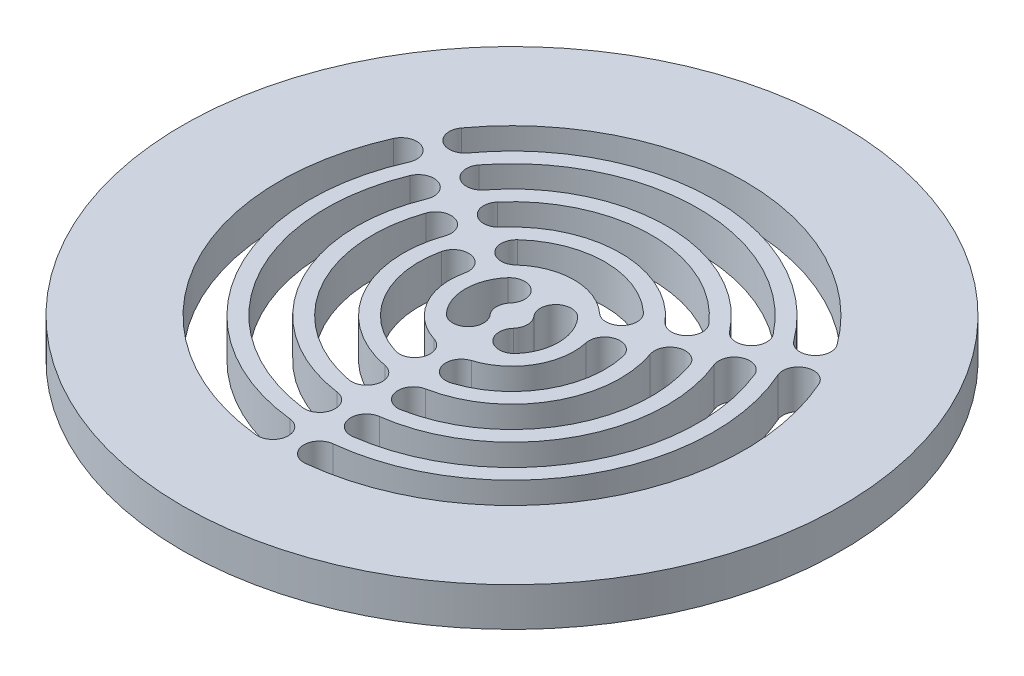
from build123d import *

# Parameters (mm, degrees)
MODEL_R                         = 42.5
AUFSATZ_LINEAR_AUSTRAGEN1_DEPTH = 5


with BuildPart() as part:
    # Model → Aufsatz-Linear austragen1 (new body)
    with BuildSketch(Plane.XZ):
        with Locations(Location((0, 0, 0), (0, 0, 270))):  # turned: the seam where the file's is
            Circle(MODEL_R)
        with BuildLine():
            ThreePointArc((4.5, -3.968626967), (6, 0), (4.5, 3.968626967))
            ThreePointArc((4.5, 3.968626967), (1.677124344, 4.145751311), (1.5, 1.322875656))
            ThreePointArc((1.5, 1.322875656), (2, 0), (1.5, -1.322875656))
            ThreePointArc((1.5, -1.322875656), (1.677124344, -4.145751311), (4.5, -3.968626967))
        make_face(mode=Mode.SUBTRACT)
        with BuildLine():
            ThreePointArc((-1.5, 1.322875656), (-1.677124344, 4.145751311), (-4.5, 3.968626967))
            ThreePointArc((-4.5, 3.968626967), (-6, 0), (-4.5, -3.968626967))
            ThreePointArc((-4.5, -3.968626967), (-1.677124344, -4.145751311), (-1.5, -1.322875656))
            ThreePointArc((-1.5, -1.322875656), (-2, 0), (-1.5, 1.322875656))
        make_face(mode=Mode.SUBTRACT)
        with BuildLine():
            ThreePointArc((-5.409084657, -5.894217775), (-8.234910265, -6.015501054), (-8.113626985, -8.841326662))
            ThreePointArc((-8.113626985, -8.841326662), (0, -12), (8.113626985, -8.841326662))
            ThreePointArc((8.113626985, -8.841326662), (8.234910265, -6.015501054), (5.409084657, -5.894217775))
            ThreePointArc((5.409084657, -5.894217775), (0, -8), (-5.409084657, -5.894217775))
        make_face(mode=Mode.SUBTRACT)
        with BuildLine():
            ThreePointArc((7.809084657, -1.737295837), (9.327031862, -4.12389096), (11.713626985, -2.605943755))
            ThreePointArc((11.713626985, -2.605943755), (10.392304845, 6), (3.6, 11.447270417))
            ThreePointArc((3.6, 11.447270417), (1.092121597, 10.139392014), (2.4, 7.631513611))
            ThreePointArc((2.4, 7.631513611), (6.92820323, 4), (7.809084657, -1.737295837))
        make_face(mode=Mode.SUBTRACT)
        with BuildLine():
            ThreePointArc((-10.59682539, -9.149168905), (-13.417681718, -8.942360836), (-13.624489787, -11.763217163))
            ThreePointArc((-13.624489787, -11.763217163), (0, -18), (13.624489787, -11.763217163))
            ThreePointArc((13.624489787, -11.763217163), (13.417681718, -8.942360836), (10.59682539, -9.149168905))
            ThreePointArc((10.59682539, -9.149168905), (0, -14), (-10.59682539, -9.149168905))
        make_face(mode=Mode.SUBTRACT)
        with BuildLine():
            ThreePointArc((13.22182539, -4.602535535), (14.453152512, -7.14887281), (16.999489787, -5.917545688))
            ThreePointArc((16.999489787, -5.917545688), (15.588457268, 9), (3.375, 17.680762851))
            ThreePointArc((3.375, 17.680762851), (1.035470794, 16.091233646), (2.625, 13.75170444))
            ThreePointArc((2.625, 13.75170444), (12.124355653, 7), (13.22182539, -4.602535535))
        make_face(mode=Mode.SUBTRACT)
        with BuildLine():
            ThreePointArc((-3.214285714, 29.827309087), (-25.980762114, 15), (-27.438350253, -12.13000146))
            ThreePointArc((-27.438350253, -12.13000146), (-24.800460139, -13.150558046), (-23.779903552, -10.512667932))
            ThreePointArc((-23.779903552, -10.512667932), (-22.516660498, 13), (-2.785714286, 25.850334542))
            ThreePointArc((-2.785714286, 25.850334542), (-1.011512728, 28.053107528), (-3.214285714, 29.827309087))
        make_face(mode=Mode.SUBTRACT)
        with BuildLine():
            ThreePointArc((-22.226821187, -9.053641252), (-19.620115984, -10.151406246), (-18.522350989, -7.544701043))
            ThreePointArc((-18.522350989, -7.544701043), (-17.320508076, 10), (-2.727272727, 19.813177016))
            ThreePointArc((-2.727272727, 19.813177016), (-1.018682298, 22.06722199), (-3.272727273, 23.775812419))
            ThreePointArc((-3.272727273, 23.775812419), (-20.784609691, 12), (-22.226821187, -9.053641252))
        make_face(mode=Mode.SUBTRACT)
        with BuildLine():
            ThreePointArc((-2.4, 7.631513611), (-1.092121597, 10.139392014), (-3.6, 11.447270417))
            ThreePointArc((-3.6, 11.447270417), (-10.392304845, 6), (-11.713626985, -2.605943755))
            ThreePointArc((-11.713626985, -2.605943755), (-9.327031862, -4.12389096), (-7.809084657, -1.737295837))
            ThreePointArc((-7.809084657, -1.737295837), (-6.92820323, 4), (-2.4, 7.631513611))
        make_face(mode=Mode.SUBTRACT)
        with BuildLine():
            ThreePointArc((-2.625, 13.75170444), (-1.035470794, 16.091233646), (-3.375, 17.680762851))
            ThreePointArc((-3.375, 17.680762851), (-15.588457268, 9), (-16.999489787, -5.917545688))
            ThreePointArc((-16.999489787, -5.917545688), (-14.453152512, -7.14887281), (-13.22182539, -4.602535535))
            ThreePointArc((-13.22182539, -4.602535535), (-12.124355653, 7), (-2.625, 13.75170444))
        make_face(mode=Mode.SUBTRACT)
        with BuildLine():
            ThreePointArc((27.438350253, -12.13000146), (25.980762114, 15), (3.214285714, 29.827309087))
            ThreePointArc((3.214285714, 29.827309087), (1.011512728, 28.053107528), (2.785714286, 25.850334542))
            ThreePointArc((2.785714286, 25.850334542), (22.516660498, 13), (23.779903552, -10.512667932))
            ThreePointArc((23.779903552, -10.512667932), (24.800460139, -13.150558046), (27.438350253, -12.13000146))
        make_face(mode=Mode.SUBTRACT)
        with BuildLine():
            ThreePointArc((-24.224064538, -17.697307627), (0, -30), (24.224064538, -17.697307627))
            ThreePointArc((24.224064538, -17.697307627), (23.788947411, -14.902549483), (20.994189267, -15.33766661))
            ThreePointArc((20.994189267, -15.33766661), (0, -26), (-20.994189267, -15.33766661))
            ThreePointArc((-20.994189267, -15.33766661), (-23.788947411, -14.902549483), (-24.224064538, -17.697307627))
        make_face(mode=Mode.SUBTRACT)
        with BuildLine():
            ThreePointArc((3.272727273, 23.775812419), (1.018682298, 22.06722199), (2.727272727, 19.813177016))
            ThreePointArc((2.727272727, 19.813177016), (17.320508076, 10), (18.522350989, -7.544701043))
            ThreePointArc((18.522350989, -7.544701043), (19.620115984, -10.151406246), (22.226821187, -9.053641252))
            ThreePointArc((22.226821187, -9.053641252), (20.784609691, 12), (3.272727273, 23.775812419))
        make_face(mode=Mode.SUBTRACT)
        with BuildLine():
            ThreePointArc((18.954093914, -14.722171167), (18.601433685, -11.915815744), (15.795078262, -12.268475973))
            ThreePointArc((15.795078262, -12.268475973), (0, -20), (-15.795078262, -12.268475973))
            ThreePointArc((-15.795078262, -12.268475973), (-18.601433685, -11.915815744), (-18.954093914, -14.722171167))
            ThreePointArc((-18.954093914, -14.722171167), (0, -24), (18.954093914, -14.722171167))
        make_face(mode=Mode.SUBTRACT)
    extrude(amount=-AUFSATZ_LINEAR_AUSTRAGEN1_DEPTH)


solid = part.part
